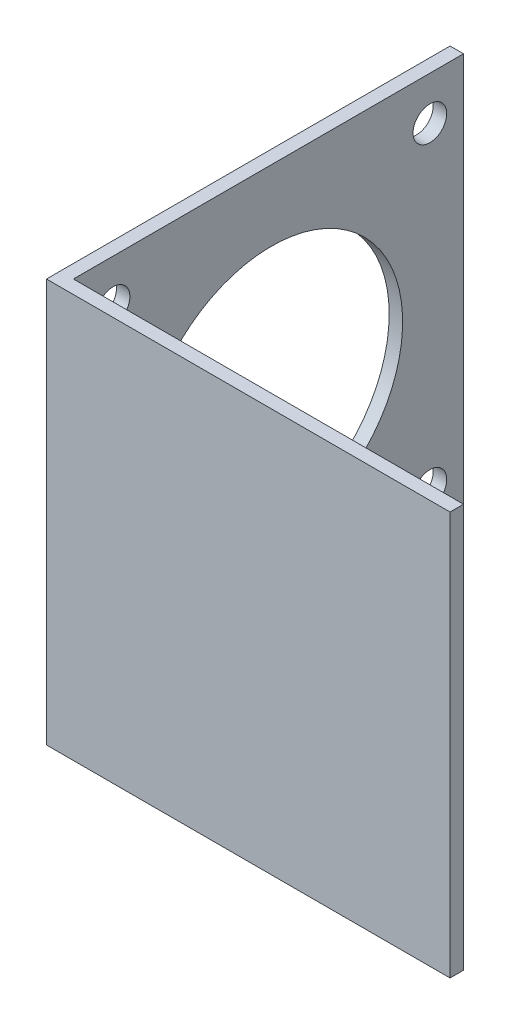
from build123d import *

# Parameters (mm, degrees)
BOSS_EXTRUDE1_DEPTH     = 60
SKETCH2_R               = 2.5
SKETCH2_R_2             = 19.5
CUT_EXTRUDE1_DEPTH      = 1
CUT_EXTRUDE1_DEPTH_BACK = 61


with BuildPart() as part:
    # Sketch1 → Boss-Extrude1 (new body)
    with BuildSketch(Plane(origin=(0, 0, 0), x_dir=(1, 0, 0), z_dir=(0, 1, 0))):
        Polygon((0, 60), (0, 0), (60, 0), (60, 2), (2, 2), (2, 60), align=None)
    extrude(amount=BOSS_EXTRUDE1_DEPTH)

    # Sketch2 → Cut-Extrude1 (cut, two sides)
    with BuildSketch(Plane.ZY) as cut_extrude1_sk:
        with Locations((-55, 53.55)):
            Circle(SKETCH2_R)
        with Locations((-7.9, 53.55)):
            Circle(SKETCH2_R)
        with Locations((-7.9, 6.45)):
            Circle(SKETCH2_R)
        with Locations((-55, 6.45)):
            Circle(SKETCH2_R)
        with Locations((-31.45, 30)):
            Circle(SKETCH2_R_2)
    extrude(amount=CUT_EXTRUDE1_DEPTH, mode=Mode.SUBTRACT)
    extrude(cut_extrude1_sk.sketch, amount=-CUT_EXTRUDE1_DEPTH_BACK, mode=Mode.SUBTRACT)


solid = part.part
